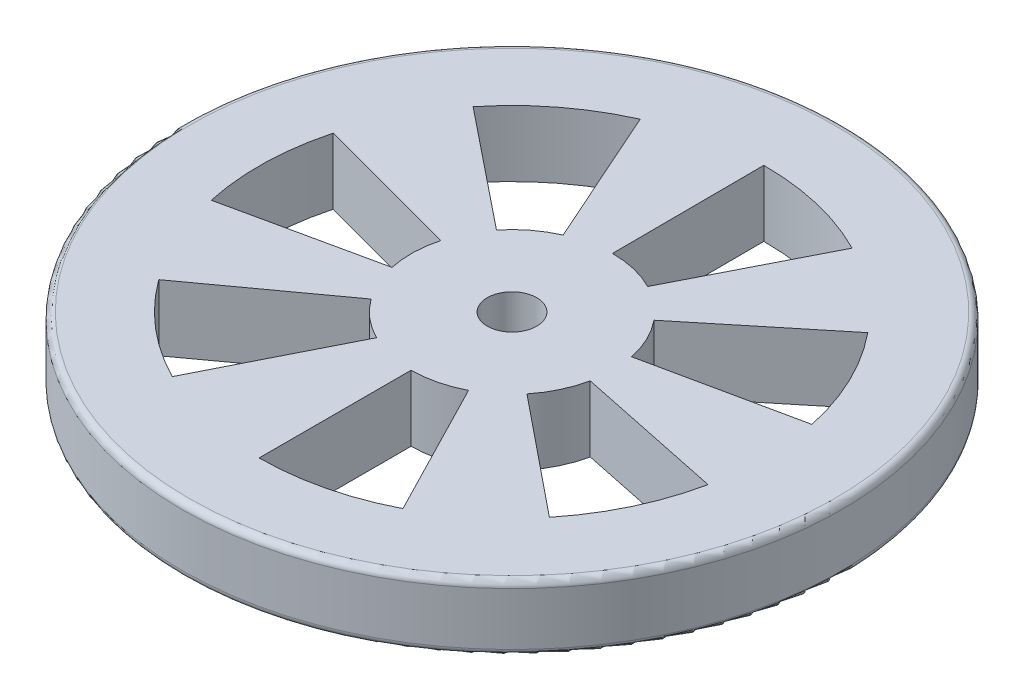
from build123d import *

# Parameters (mm, degrees)
SKETCH1_R           = 100
BOSS_EXTRUDE1_DEPTH = 20
FILLET1_R           = 2
SKETCH2_R           = 7.5
CUT_EXTRUDE1_DEPTH  = 21
CUT_EXTRUDE2_DEPTH  = 21
CIRPATTERN1_COUNT   = 7
CIRPATTERN1_ANGLE   = 306


with BuildPart() as part:
    # Sketch1 → Boss-Extrude1 (new body)
    with BuildSketch(Plane(origin=(0, 0, 0), x_dir=(1, 0, 0), z_dir=(0, 1, 0))):
        Circle(SKETCH1_R)
    extrude(amount=BOSS_EXTRUDE1_DEPTH)

    # Fillet1
    fillet1_edges = [part.edges().sort_by_distance(p)[0] for p in [
        (-100, 0, 0),
        (-100, 20, 0),
    ]]
    fillet(fillet1_edges, radius=FILLET1_R)

    # Sketch2 → Cut-Extrude1 (cut, through all)
    with BuildSketch(Plane(origin=(0, 20, 0), x_dir=(1, 0, 0), z_dir=(0, 1, 0))):
        Circle(SKETCH2_R)
    extrude(amount=-CUT_EXTRUDE1_DEPTH, mode=Mode.SUBTRACT)

    # Sketch3 → Cut-Extrude2 (cut, through all)
    with BuildSketch(Plane.XZ):
        with BuildLine():
            Line((0, 30.617728898), (0, 76.732128088))
            ThreePointArc((0, 76.732128088), (18.073615255, 74.573211762), (35.130200903, 68.217948265))
            Line((35.130200903, 68.217948265), (14.017687169, 27.220392527))
            ThreePointArc((14.017687169, 27.220392527), (7.21175166, 29.756275991), (0, 30.617728898))
        make_face()
    cut_extrude2 = extrude(amount=-CUT_EXTRUDE2_DEPTH, mode=Mode.SUBTRACT)

    # CirPattern1: Cut-Extrude2 ×7 about axis
    cirpattern1_axis = Axis((0, 0, 0), (0, 1, 0))
    for i in range(1, CIRPATTERN1_COUNT):
        add(cut_extrude2.rotate(cirpattern1_axis, i * CIRPATTERN1_ANGLE / (CIRPATTERN1_COUNT - 1)), mode=Mode.SUBTRACT)


solid = part.part
